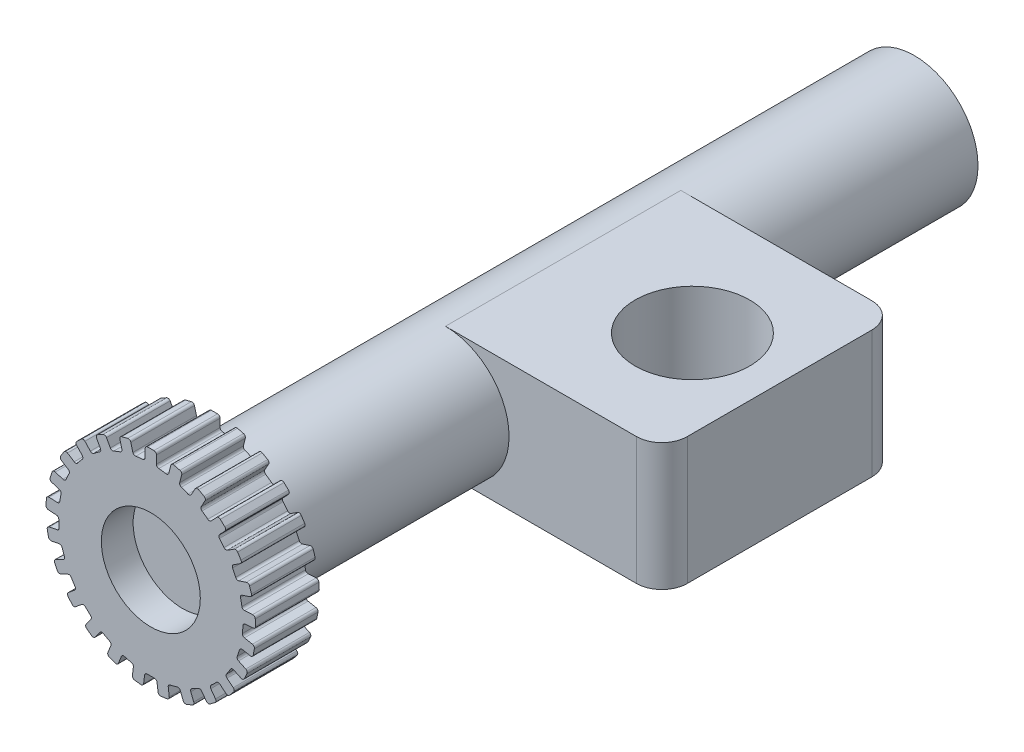
from build123d import *

# Parameters (mm, degrees)
SKETCH1_R                = 5
BOSS_EXTRUDE1_DEPTH      = 55
BOSS_EXTRUDE2_DEPTH      = 5
BOSS_EXTRUDE3_DEPTH      = 5
BOSS_EXTRUDE3_DEPTH_BACK = 5
SKETCH4_R                = 4.501832036
CUT_EXTRUDE1_DEPTH       = 50
SKETCH5_R                = 3.889673249
CUT_EXTRUDE2_DEPTH       = 2.5


with BuildPart() as part:
    # Sketch1 → Boss-Extrude1 (new body)
    with BuildSketch(Plane.XY):
        Circle(SKETCH1_R)
    extrude(amount=BOSS_EXTRUDE1_DEPTH)

    # Sketch2 → Boss-Extrude2 (add)
    with BuildSketch(Plane.XY.offset(55)):
        with BuildLine():
            Line((2.428467308, 7.674410894), (2.271896443, 7.064607637))
            ThreePointArc((2.271896443, 7.064607637), (2.289215867, 6.920614554), (2.399293631, 6.826185449))
            ThreePointArc((2.399293631, 6.826185449), (2.663589557, 6.727459281), (2.923835709, 6.618504548))
            ThreePointArc((2.923835709, 6.618504548), (3.068720116, 6.611986989), (3.179915481, 6.705097467))
            Line((3.179915481, 6.705097467), (3.483219287, 7.256805043))
            ThreePointArc((3.483219287, 7.256805043), (3.602682402, 7.352513045), (3.754831358, 7.335715644))
            Line((3.754831358, 7.335715644), (4.18181032, 7.100981974))
            ThreePointArc((4.18181032, 7.100981974), (4.277518322, 6.981518859), (4.260720921, 6.829369903))
            Line((4.260720921, 6.829369903), (3.957417114, 6.277662327))
            ThreePointArc((3.957417114, 6.277662327), (3.938382793, 6.133885887), (4.021518699, 6.015048218))
            ThreePointArc((4.021518699, 6.015048218), (4.252959083, 5.85369599), (4.477933183, 5.683443685))
            ThreePointArc((4.477933183, 5.683443685), (4.616644929, 5.6410996), (4.747502521, 5.703631678))
            Line((4.747502521, 5.703631678), (5.178481575, 6.162577757))
            ThreePointArc((5.178481575, 6.162577757), (5.317993149, 6.225569648), (5.461184722, 6.171462061))
            Line((5.461184722, 6.171462061), (5.816373465, 5.837917631))
            ThreePointArc((5.816373465, 5.837917631), (5.879365355, 5.698406057), (5.825257769, 5.555214484))
            Line((5.825257769, 5.555214484), (5.394278714, 5.096268405))
            ThreePointArc((5.394278714, 5.096268405), (5.340086645, 4.96174261), (5.391056956, 4.825963386))
            ThreePointArc((5.391056956, 4.825963386), (5.575099548, 4.612123452), (5.750665646, 4.391271153))
            ThreePointArc((5.750665646, 4.391271153), (5.874488962, 4.315761176), (6.016786518, 4.343785735))
            Line((6.016786518, 4.343785735), (6.548360821, 4.681133046))
            ThreePointArc((6.548360821, 4.681133046), (6.699154828, 4.707450813), (6.824391765, 4.61943282))
            Line((6.824391765, 4.61943282), (7.085472473, 4.208035452))
            ThreePointArc((7.085472473, 4.208035452), (7.111790241, 4.057241445), (7.023772247, 3.932004508))
            Line((7.023772247, 3.932004508), (6.492197944, 3.594657197))
            ThreePointArc((6.492197944, 3.594657197), (6.406253213, 3.477834796), (6.421855278, 3.333645526))
            ThreePointArc((6.421855278, 3.333645526), (6.546936005, 3.080754235), (6.662062637, 2.823178904))
            ThreePointArc((6.662062637, 2.823178904), (6.763217249, 2.719247605), (6.908013689, 2.711003758))
            Line((6.908013689, 2.711003758), (7.506782473, 2.905555529))
            ThreePointArc((7.506782473, 2.905555529), (7.659383972, 2.893545531), (7.758797175, 2.777147625))
            Line((7.758797175, 2.777147625), (7.909365188, 2.313746931))
            ThreePointArc((7.909365188, 2.313746931), (7.89735519, 2.161145432), (7.780957284, 2.061732229))
            Line((7.780957284, 2.061732229), (7.1821885, 1.867180457))
            ThreePointArc((7.1821885, 1.867180457), (7.069891331, 1.775401832), (7.049144816, 1.631862457))
            ThreePointArc((7.049144816, 1.631862457), (7.107404394, 1.3558099), (7.154857732, 1.077695941))
            ThreePointArc((7.154857732, 1.077695941), (7.226987722, 0.951873707), (7.365184955, 0.907879445))
            Line((7.365184955, 0.907879445), (7.993525375, 0.947411273))
            ThreePointArc((7.993525375, 0.947411273), (8.138345852, 0.897828141), (8.205688824, 0.760364031))
            Line((8.205688824, 0.760364031), (8.2362834, 0.27407718))
            ThreePointArc((8.2362834, 0.27407718), (8.186700268, 0.129256703), (8.049236158, 0.06191373))
            Line((8.049236158, 0.06191373), (7.420895738, 0.022381902))
            ThreePointArc((7.420895738, 0.022381902), (7.289302175, -0.038586158), (7.233510659, -0.172456532))
            ThreePointArc((7.233510659, -0.172456532), (7.221288427, -0.454324959), (7.198086802, -0.73550262))
            ThreePointArc((7.198086802, -0.73550262), (7.236659978, -0.875309917), (7.359574563, -0.952290273))
            Line((7.359574563, -0.952290273), (7.978005679, -1.070262318))
            ThreePointArc((7.978005679, -1.070262318), (8.105945531, -1.154303092), (8.136986866, -1.304196031))
            Line((8.136986866, -1.304196031), (8.045685634, -1.782813848))
            ThreePointArc((8.045685634, -1.782813848), (7.96164486, -1.9107537), (7.811751921, -1.941795035))
            Line((7.811751921, -1.941795035), (7.193320805, -1.82382299))
            ThreePointArc((7.193320805, -1.82382299), (7.050699356, -1.850149639), (6.963368425, -1.965939442))
            ThreePointArc((6.963368425, -1.965939442), (6.881432349, -2.235912908), (6.789033605, -2.502486848))
            ThreePointArc((6.789033605, -2.502486848), (6.791626273, -2.6474946), (6.891535034, -2.75262409))
            Line((6.891535034, -2.75262409), (7.461198545, -3.020687391))
            ThreePointArc((7.461198545, -3.020687391), (7.56421884, -3.133905217), (7.557008097, -3.28680866))
            Line((7.557008097, -3.28680866), (7.34954785, -3.727684125))
            ThreePointArc((7.34954785, -3.727684125), (7.236330024, -3.830704421), (7.083426582, -3.823493677))
            Line((7.083426582, -3.823493677), (6.513763071, -3.555430377))
            ThreePointArc((6.513763071, -3.555430377), (6.369075166, -3.545461413), (6.255692143, -3.635895147))
            ThreePointArc((6.255692143, -3.635895147), (6.109190569, -3.877010227), (5.953400458, -4.112230623))
            ThreePointArc((5.953400458, -4.112230623), (5.919849712, -4.25332746), (5.990475014, -4.380000413))
            Line((5.990475014, -4.380000413), (6.475576866, -4.781311566))
            ThreePointArc((6.475576866, -4.781311566), (6.547204461, -4.916592552), (6.502194716, -5.062899012))
            Line((6.502194716, -5.062899012), (6.191610945, -5.438330299))
            ThreePointArc((6.191610945, -5.438330299), (6.056329959, -5.509957894), (5.910023499, -5.46494815))
            Line((5.910023499, -5.46494815), (5.424921647, -5.063636997))
            ThreePointArc((5.424921647, -5.063636997), (5.287258559, -5.017998807), (5.154947717, -5.077394189))
            ThreePointArc((5.154947717, -5.077394189), (4.953085877, -5.274500735), (4.743693266, -5.463587824))
            ThreePointArc((4.743693266, -5.463587824), (4.676107221, -5.591908114), (4.713011417, -5.732165201))
            Line((4.713011417, -5.732165201), (5.083070877, -6.241508351))
            ThreePointArc((5.083070877, -6.241508351), (5.118805146, -6.390352294), (5.038824529, -6.5208688))
            Line((5.038824529, -6.5208688), (4.644632353, -6.80726618))
            ThreePointArc((4.644632353, -6.80726618), (4.49578841, -6.843000449), (4.365271904, -6.763019831))
            Line((4.365271904, -6.763019831), (3.995212444, -6.253676681))
            ThreePointArc((3.995212444, -6.253676681), (3.873224051, -6.175236882), (3.730298967, -6.199861879))
            ThreePointArc((3.730298967, -6.199861879), (3.485760584, -6.340574963), (3.235922379, -6.471647709))
            ThreePointArc((3.235922379, -6.471647709), (3.138547716, -6.579128615), (3.13941198, -6.724156968))
            Line((3.13941198, -6.724156968), (3.371176851, -7.309528212))
            ThreePointArc((3.371176851, -7.309528212), (3.368772479, -7.4625827), (3.258846464, -7.569108419))
            Line((3.258846464, -7.569108419), (2.805814429, -7.748476491))
            ThreePointArc((2.805814429, -7.748476491), (2.65275994, -7.746072119), (2.546234221, -7.636146104))
            Line((2.546234221, -7.636146104), (2.31446935, -7.050774861))
            ThreePointArc((2.31446935, -7.050774861), (2.215820632, -6.944462112), (2.071261814, -6.932769447))
            ThreePointArc((2.071261814, -6.932769447), (1.799412133, -7.008247547), (1.524826589, -7.073070167))
            ThreePointArc((1.524826589, -7.073070167), (1.403781715, -7.152958268), (1.368551742, -7.293645223))
            Line((1.368551742, -7.293645223), (1.447459385, -7.918263532))
            ThreePointArc((1.447459385, -7.918263532), (1.407067447, -8.06591159), (1.274103091, -8.141753119))
            Line((1.274103091, -8.141753119), (0.790696865, -8.202821527))
            ThreePointArc((0.790696865, -8.202821527), (0.643048808, -8.16242959), (0.567207278, -8.029465234))
            Line((0.567207278, -8.029465234), (0.488299635, -7.404846925))
            ThreePointArc((0.488299635, -7.404846925), (0.419189053, -7.277341247), (0.282079664, -7.230065613))
            ThreePointArc((0.282079664, -7.230065613), (0, -7.235566164), (-0.282079664, -7.230065613))
            ThreePointArc((-0.282079664, -7.230065613), (-0.419189053, -7.277341247), (-0.488299635, -7.404846925))
            Line((-0.488299635, -7.404846925), (-0.567207278, -8.029465234))
            ThreePointArc((-0.567207278, -8.029465234), (-0.643048808, -8.16242959), (-0.790696865, -8.202821527))
            Line((-0.790696865, -8.202821527), (-1.274103091, -8.141753119))
            ThreePointArc((-1.274103091, -8.141753119), (-1.407067447, -8.06591159), (-1.447459385, -7.918263532))
            Line((-1.447459385, -7.918263532), (-1.368551742, -7.293645223))
            ThreePointArc((-1.368551742, -7.293645223), (-1.403781715, -7.152958268), (-1.524826589, -7.073070167))
            ThreePointArc((-1.524826589, -7.073070167), (-1.799412133, -7.008247547), (-2.071261814, -6.932769447))
            ThreePointArc((-2.071261814, -6.932769447), (-2.215820632, -6.944462112), (-2.31446935, -7.050774861))
            Line((-2.31446935, -7.050774861), (-2.546234221, -7.636146104))
            ThreePointArc((-2.546234221, -7.636146104), (-2.65275994, -7.746072119), (-2.805814429, -7.748476491))
            Line((-2.805814429, -7.748476491), (-3.258846464, -7.569108419))
            ThreePointArc((-3.258846464, -7.569108419), (-3.368772479, -7.4625827), (-3.371176851, -7.309528212))
            Line((-3.371176851, -7.309528212), (-3.13941198, -6.724156968))
            ThreePointArc((-3.13941198, -6.724156968), (-3.138547716, -6.579128615), (-3.235922379, -6.471647709))
            ThreePointArc((-3.235922379, -6.471647709), (-3.485760584, -6.340574963), (-3.730298967, -6.199861879))
            ThreePointArc((-3.730298967, -6.199861879), (-3.873224051, -6.175236882), (-3.995212444, -6.253676681))
            Line((-3.995212444, -6.253676681), (-4.365271904, -6.763019831))
            ThreePointArc((-4.365271904, -6.763019831), (-4.49578841, -6.843000449), (-4.644632353, -6.80726618))
            Line((-4.644632353, -6.80726618), (-5.038824529, -6.5208688))
            ThreePointArc((-5.038824529, -6.5208688), (-5.118805146, -6.390352294), (-5.083070877, -6.241508351))
            Line((-5.083070877, -6.241508351), (-4.713011417, -5.732165201))
            ThreePointArc((-4.713011417, -5.732165201), (-4.676107221, -5.591908114), (-4.743693266, -5.463587824))
            ThreePointArc((-4.743693266, -5.463587824), (-4.953085877, -5.274500735), (-5.154947717, -5.077394189))
            ThreePointArc((-5.154947717, -5.077394189), (-5.287258559, -5.017998807), (-5.424921647, -5.063636997))
            Line((-5.424921647, -5.063636997), (-5.910023499, -5.46494815))
            ThreePointArc((-5.910023499, -5.46494815), (-6.056329959, -5.509957894), (-6.191610945, -5.438330299))
            Line((-6.191610945, -5.438330299), (-6.502194716, -5.062899012))
            ThreePointArc((-6.502194716, -5.062899012), (-6.547204461, -4.916592552), (-6.475576866, -4.781311566))
            Line((-6.475576866, -4.781311566), (-5.990475014, -4.380000413))
            ThreePointArc((-5.990475014, -4.380000413), (-5.919849712, -4.25332746), (-5.953400458, -4.112230623))
            ThreePointArc((-5.953400458, -4.112230623), (-6.109190569, -3.877010227), (-6.255692143, -3.635895147))
            ThreePointArc((-6.255692143, -3.635895147), (-6.369075166, -3.545461413), (-6.513763071, -3.555430377))
            Line((-6.513763071, -3.555430377), (-7.083426582, -3.823493677))
            ThreePointArc((-7.083426582, -3.823493677), (-7.236330024, -3.830704421), (-7.34954785, -3.727684125))
            Line((-7.34954785, -3.727684125), (-7.557008097, -3.28680866))
            ThreePointArc((-7.557008097, -3.28680866), (-7.56421884, -3.133905217), (-7.461198545, -3.020687391))
            Line((-7.461198545, -3.020687391), (-6.891535034, -2.75262409))
            ThreePointArc((-6.891535034, -2.75262409), (-6.791626273, -2.6474946), (-6.789033605, -2.502486848))
            ThreePointArc((-6.789033605, -2.502486848), (-6.881432349, -2.235912908), (-6.963368425, -1.965939442))
            ThreePointArc((-6.963368425, -1.965939442), (-7.050699356, -1.850149639), (-7.193320805, -1.82382299))
            Line((-7.193320805, -1.82382299), (-7.811751921, -1.941795035))
            ThreePointArc((-7.811751921, -1.941795035), (-7.96164486, -1.9107537), (-8.045685634, -1.782813848))
            Line((-8.045685634, -1.782813848), (-8.136986866, -1.304196031))
            ThreePointArc((-8.136986866, -1.304196031), (-8.105945531, -1.154303092), (-7.978005679, -1.070262318))
            Line((-7.978005679, -1.070262318), (-7.359574563, -0.952290273))
            ThreePointArc((-7.359574563, -0.952290273), (-7.236659978, -0.875309917), (-7.198086802, -0.73550262))
            ThreePointArc((-7.198086802, -0.73550262), (-7.221288427, -0.454324959), (-7.233510659, -0.172456532))
            ThreePointArc((-7.233510659, -0.172456532), (-7.289302175, -0.038586158), (-7.420895738, 0.022381902))
            Line((-7.420895738, 0.022381902), (-8.049236158, 0.06191373))
            ThreePointArc((-8.049236158, 0.06191373), (-8.186700268, 0.129256703), (-8.2362834, 0.27407718))
            Line((-8.2362834, 0.27407718), (-8.205688824, 0.760364031))
            ThreePointArc((-8.205688824, 0.760364031), (-8.138345852, 0.897828141), (-7.993525375, 0.947411273))
            Line((-7.993525375, 0.947411273), (-7.365184955, 0.907879445))
            ThreePointArc((-7.365184955, 0.907879445), (-7.226987722, 0.951873707), (-7.154857732, 1.077695941))
            ThreePointArc((-7.154857732, 1.077695941), (-7.107404394, 1.3558099), (-7.049144816, 1.631862457))
            ThreePointArc((-7.049144816, 1.631862457), (-7.069891331, 1.775401832), (-7.1821885, 1.867180457))
            Line((-7.1821885, 1.867180457), (-7.780957284, 2.061732229))
            ThreePointArc((-7.780957284, 2.061732229), (-7.89735519, 2.161145432), (-7.909365188, 2.313746931))
            Line((-7.909365188, 2.313746931), (-7.758797175, 2.777147625))
            ThreePointArc((-7.758797175, 2.777147625), (-7.659383972, 2.893545531), (-7.506782473, 2.905555529))
            Line((-7.506782473, 2.905555529), (-6.908013689, 2.711003758))
            ThreePointArc((-6.908013689, 2.711003758), (-6.763217249, 2.719247605), (-6.662062637, 2.823178904))
            ThreePointArc((-6.662062637, 2.823178904), (-6.546936005, 3.080754235), (-6.421855278, 3.333645526))
            ThreePointArc((-6.421855278, 3.333645526), (-6.406253213, 3.477834796), (-6.492197944, 3.594657197))
            Line((-6.492197944, 3.594657197), (-7.023772247, 3.932004508))
            ThreePointArc((-7.023772247, 3.932004508), (-7.111790241, 4.057241445), (-7.085472473, 4.208035452))
            Line((-7.085472473, 4.208035452), (-6.824391765, 4.61943282))
            ThreePointArc((-6.824391765, 4.61943282), (-6.699154828, 4.707450813), (-6.548360821, 4.681133046))
            Line((-6.548360821, 4.681133046), (-6.016786518, 4.343785735))
            ThreePointArc((-6.016786518, 4.343785735), (-5.874488962, 4.315761176), (-5.750665646, 4.391271153))
            ThreePointArc((-5.750665646, 4.391271153), (-5.575099548, 4.612123452), (-5.391056956, 4.825963386))
            ThreePointArc((-5.391056956, 4.825963386), (-5.340086645, 4.96174261), (-5.394278714, 5.096268405))
            Line((-5.394278714, 5.096268405), (-5.825257769, 5.555214484))
            ThreePointArc((-5.825257769, 5.555214484), (-5.879365355, 5.698406057), (-5.816373465, 5.837917631))
            Line((-5.816373465, 5.837917631), (-5.461184722, 6.171462061))
            ThreePointArc((-5.461184722, 6.171462061), (-5.317993149, 6.225569648), (-5.178481575, 6.162577757))
            Line((-5.178481575, 6.162577757), (-4.747502521, 5.703631678))
            ThreePointArc((-4.747502521, 5.703631678), (-4.616644929, 5.6410996), (-4.477933183, 5.683443685))
            ThreePointArc((-4.477933183, 5.683443685), (-4.252959083, 5.85369599), (-4.021518699, 6.015048218))
            ThreePointArc((-4.021518699, 6.015048218), (-3.938382793, 6.133885887), (-3.957417114, 6.277662327))
            Line((-3.957417114, 6.277662327), (-4.260720921, 6.829369903))
            ThreePointArc((-4.260720921, 6.829369903), (-4.277518322, 6.981518859), (-4.18181032, 7.100981974))
            Line((-4.18181032, 7.100981974), (-3.754831358, 7.335715644))
            ThreePointArc((-3.754831358, 7.335715644), (-3.602682402, 7.352513045), (-3.483219287, 7.256805043))
            Line((-3.483219287, 7.256805043), (-3.179915481, 6.705097467))
            ThreePointArc((-3.179915481, 6.705097467), (-3.068720116, 6.611986989), (-2.923835709, 6.618504548))
            ThreePointArc((-2.923835709, 6.618504548), (-2.663589557, 6.727459281), (-2.399293631, 6.826185449))
            ThreePointArc((-2.399293631, 6.826185449), (-2.289215867, 6.920614554), (-2.271896443, 7.064607637))
            Line((-2.271896443, 7.064607637), (-2.428467308, 7.674410894))
            ThreePointArc((-2.428467308, 7.674410894), (-2.406899081, 7.825957155), (-2.284488653, 7.917865504))
            Line((-2.284488653, 7.917865504), (-1.81254813, 8.039039235))
            ThreePointArc((-1.81254813, 8.039039235), (-1.66100187, 8.017471008), (-1.569093521, 7.89506058))
            Line((-1.569093521, 7.89506058), (-1.412522656, 7.285257323))
            ThreePointArc((-1.412522656, 7.285257323), (-1.327976333, 7.167418919), (-1.186022884, 7.13770043))
            ThreePointArc((-1.186022884, 7.13770043), (-0.906856904, 7.178511563), (-0.626312121, 7.208408343))
            ThreePointArc((-0.626312121, 7.208408343), (-0.496209088, 7.272495558), (-0.443624162, 7.407657667))
            Line((-0.443624162, 7.407657667), (-0.443624162, 8.037240424))
            ThreePointArc((-0.443624162, 8.037240424), (-0.385045519, 8.178661781), (-0.243624162, 8.237240424))
            Line((-0.243624162, 8.237240424), (0.243624162, 8.237240424))
            ThreePointArc((0.243624162, 8.237240424), (0.385045519, 8.178661781), (0.443624162, 8.037240424))
            Line((0.443624162, 8.037240424), (0.443624162, 7.407657667))
            ThreePointArc((0.443624162, 7.407657667), (0.496209088, 7.272495558), (0.626312121, 7.208408343))
            ThreePointArc((0.626312121, 7.208408343), (0.906856904, 7.178511563), (1.186022884, 7.13770043))
            ThreePointArc((1.186022884, 7.13770043), (1.327976333, 7.167418919), (1.412522656, 7.285257323))
            Line((1.412522656, 7.285257323), (1.569093521, 7.89506058))
            ThreePointArc((1.569093521, 7.89506058), (1.66100187, 8.017471008), (1.81254813, 8.039039235))
            Line((1.81254813, 8.039039235), (2.284488653, 7.917865504))
            ThreePointArc((2.284488653, 7.917865504), (2.406899081, 7.825957155), (2.428467308, 7.674410894))
        make_face()
    extrude(amount=BOSS_EXTRUDE2_DEPTH)

    # Sketch3 → Boss-Extrude3 (add, two sides: drawn at the far end of the back side and taken through both)
    with BuildSketch(Plane(origin=(0, 0, 0), x_dir=(1, 0, 0), z_dir=(0, 1, 0)).offset(-BOSS_EXTRUDE3_DEPTH_BACK)):
        with BuildLine():
            Line((5, -18.355044708), (0.719319044, -18.355044708))
            Line((0.719319044, -18.355044708), (0, -18.355044708))
            Line((0, -18.355044708), (0, -27.602149903))
            Line((0, -27.602149903), (0, -36.849255099))
            Line((0, -36.849255099), (0.719319044, -36.849255099))
            Line((0.719319044, -36.849255099), (5, -36.849255099))
            Line((5, -36.849255099), (15.008297928, -36.849255099))
            ThreePointArc((15.008297928, -36.849255099), (16.42251149, -36.263468661), (17.008297928, -34.849255099))
            Line((17.008297928, -34.849255099), (17.008297928, -20.355044708))
            ThreePointArc((17.008297928, -20.355044708), (16.42251149, -18.940831146), (15.008297928, -18.355044708))
            Line((15.008297928, -18.355044708), (5, -18.355044708))
        make_face()
    extrude(amount=BOSS_EXTRUDE3_DEPTH + BOSS_EXTRUDE3_DEPTH_BACK)

    # Sketch4 → Cut-Extrude1 (cut)
    with BuildSketch(Plane(origin=(0, 5, 0), x_dir=(1, 0, 0), z_dir=(0, 1, 0))):
        with Locations((10.161187897, -27.602149903)):
            Circle(SKETCH4_R)
    extrude(amount=-CUT_EXTRUDE1_DEPTH, mode=Mode.SUBTRACT)

    # Sketch5 → Cut-Extrude2 (cut)
    with BuildSketch(Plane.XY.offset(60)):
        Circle(SKETCH5_R)
    extrude(amount=-CUT_EXTRUDE2_DEPTH, mode=Mode.SUBTRACT)


solid = part.part
